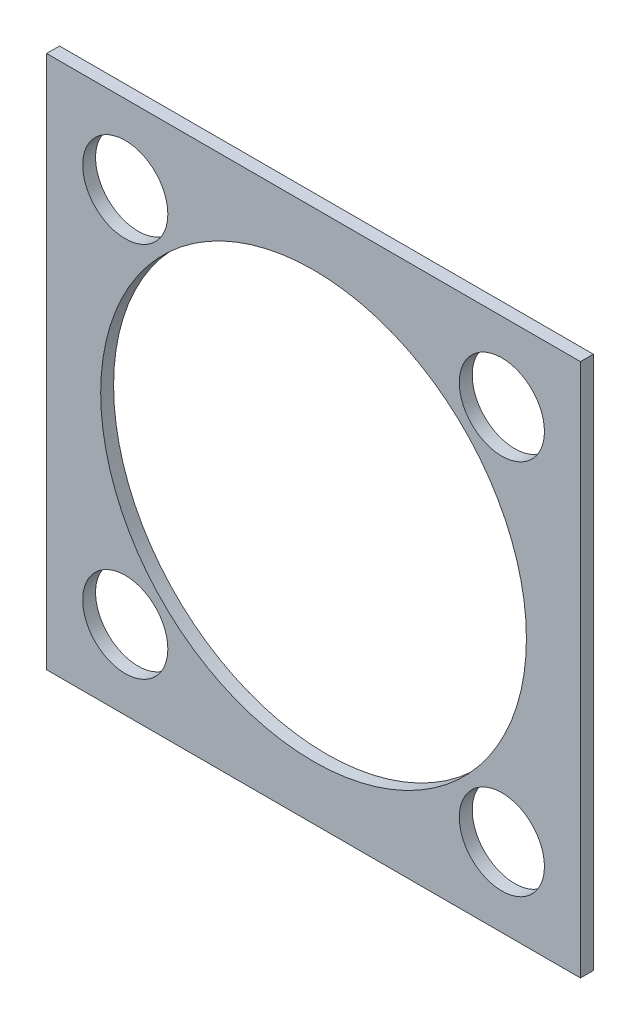
from build123d import *

# Parameters (mm, degrees)
BOSS_EXTRUDE1_DEPTH      = 0.499999
BOSS_EXTRUDE1_DEPTH_BACK = 0.499999
SKETCH1_W                = 41.402
SKETCH1_H                = 41.402
SKETCH3_R                = 16.51
CUT_EXTRUDE1_DEPTH       = 30.292708956
SKETCH6_R                = 3.302
CUT_EXTRUDE2_DEPTH       = 30.292708956


with BuildPart() as part:
    # Sketch1 → Boss-Extrude1 (new, two sides: drawn at the far end of the back side and taken through both)
    with BuildSketch(Plane.XY.offset(-BOSS_EXTRUDE1_DEPTH_BACK)):
        Rectangle(SKETCH1_W, SKETCH1_H)
    extrude(amount=BOSS_EXTRUDE1_DEPTH + BOSS_EXTRUDE1_DEPTH_BACK)

    # Sketch3 → Cut-Extrude1 (cut, through all)
    with BuildSketch(Plane.XY.offset(0.499999)):
        Circle(SKETCH3_R)
    extrude(amount=-CUT_EXTRUDE1_DEPTH, mode=Mode.SUBTRACT)

    # Sketch6 → Cut-Extrude2 (cut, through all)
    with BuildSketch(Plane.XY.offset(0.499999)):
        with Locations((-14.605, 14.605)):
            Circle(SKETCH6_R)
        with Locations((14.605, 14.605)):
            Circle(SKETCH6_R)
    cut_extrude2 = extrude(amount=-CUT_EXTRUDE2_DEPTH, mode=Mode.SUBTRACT)

    # Mirror1: Cut-Extrude2 across plane
    add(cut_extrude2.mirror(Plane.ZX), mode=Mode.SUBTRACT)


solid = part.part
